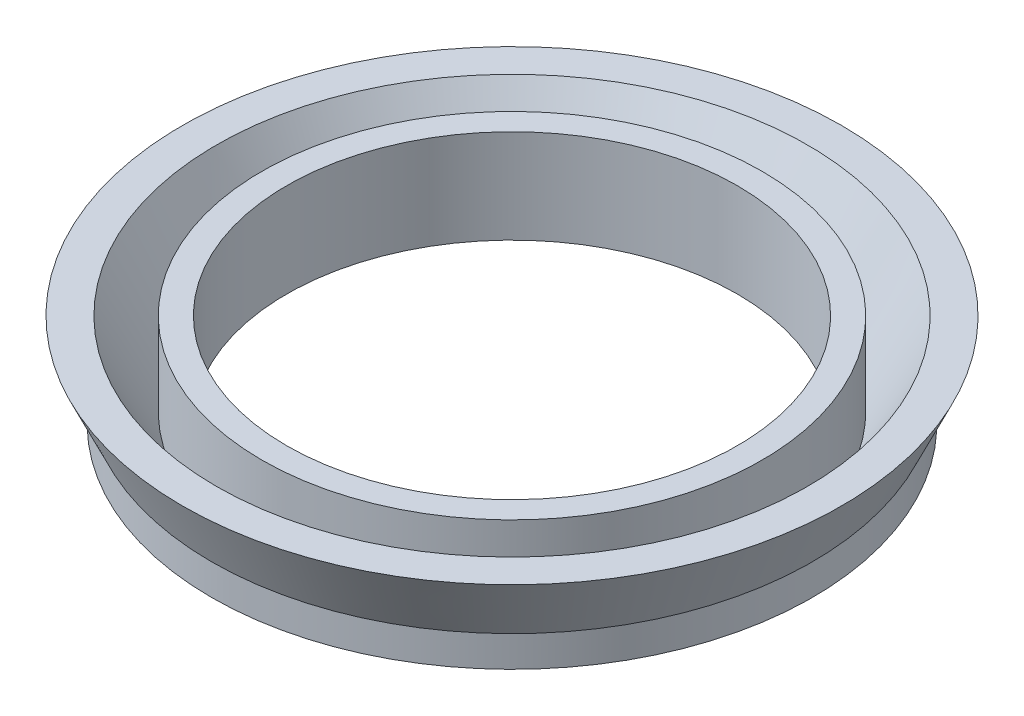
from build123d import *


with BuildPart() as part:
    # Croquis1 → Revolución1 (revolve)
    with BuildSketch(Plane.XY):
        Polygon((12, 0), (16, 0), (16, 1.645714286), (17.552497275, 5), (15.747042228, 5), (13.322419144, 0.563237404), (13.322419144, 5), (12, 5), align=None)
    revolve(axis=Axis((0, 18.742857143, 0), (0, -1, 0)))


solid = part.part
